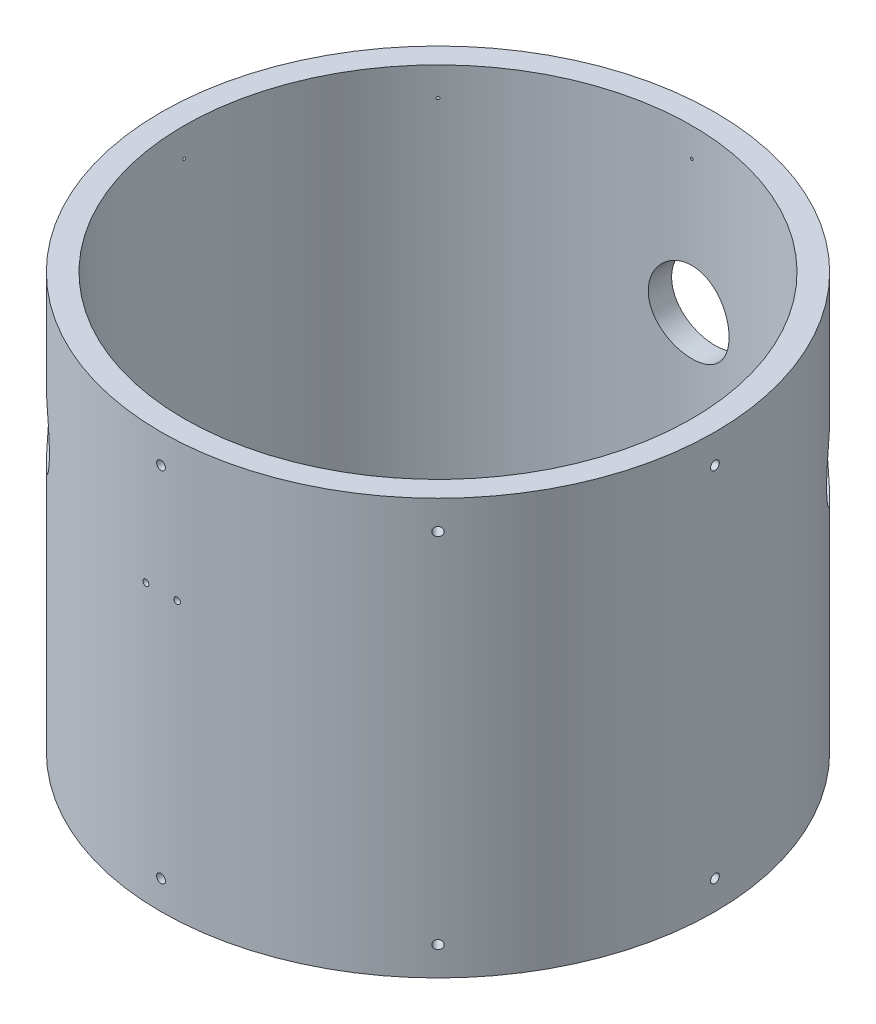
from build123d import *

# Parameters (mm, degrees)
SKETCH1_R                       = 152.4
SKETCH1_R_2                     = 139.7
BOSS_EXTRUDE1_DEPTH             = 228.6
F_10_32_TAPPED_HOLE1_AT_2_COUNT = 2
F_10_32_TAPPED_HOLE1_AT_2_PITCH = 196.85
CIRPATTERN1_COUNT               = 8
F_8_32_TAPPED_HOLE1_D           = 3.4544
F_8_32_TAPPED_HOLE1_DEPTH       = 10.668
F_8_32_TAPPED_HOLE1_TIP         = 1.037806461
PRESSURE_RELIF_HOLE_REACH       = 435.16
PRESSURE_RELIF_HOLE_BORE_R      = 19.05
VENT_VALVE_HOLE_D               = 38.1
VENT_VALVE_HOLE_DEPTH           = 25.4
HELIUM_IN_REACH                 = 412.35
HELIUM_IN_BORE_R                = 22.225


with BuildPart() as part:
    # Sketch1 → Boss-Extrude1 (new body)
    with BuildSketch(Plane(origin=(0, 0, 0), x_dir=(1, 0, 0), z_dir=(0, 1, 0))):
        with Locations(Location((0, 0, 0), (0, 0, 270))):
            Circle(SKETCH1_R)
        with Locations(Location((0, 0, 0), (0, 0, 270))):
            Circle(SKETCH1_R_2, mode=Mode.SUBTRACT)
    extrude(amount=BOSS_EXTRUDE1_DEPTH)

    # Sketch3 → #10-32 Tapped Hole1 (revolve, cut)
    with BuildSketch(Plane(origin=(0, 212.725, 152.4), x_dir=(0, -1, 0), z_dir=(1, 0, 0))):
        Polygon((0, 0), (0, 13.151317848), (2.0193, 11.938), (2.0193, 9.652), (2.413, 9.652), (2.413, 0), align=None)
    f_10_32_tapped_hole1 = revolve(axis=Axis((0, 212.725, 158.75), (0, 0, -1)), mode=Mode.SUBTRACT)

    # #10-32 Tapped Hole1 at 2: #10-32 Tapped Hole1 ×2
    with Locations(*[(0, -i * F_10_32_TAPPED_HOLE1_AT_2_PITCH, 0) for i in range(1, F_10_32_TAPPED_HOLE1_AT_2_COUNT)]):
        add(f_10_32_tapped_hole1, mode=Mode.SUBTRACT)

    # CirPattern1: #10-32 Tapped Hole1 ×8 about axis
    cirpattern1_axis = Axis((0, 0, 0), (0, 1, 0))
    for i in range(1, CIRPATTERN1_COUNT):
        add(f_10_32_tapped_hole1.rotate(cirpattern1_axis, i * 360 / CIRPATTERN1_COUNT), mode=Mode.SUBTRACT)

    # CirPattern1 copy 1 sketch → CirPattern1 copy 1 (revolve, cut)
    with BuildSketch(Plane(origin=(107.763073453, 15.875, 107.763073453), x_dir=(0, -1, 0), z_dir=(0.7071067811865476, 0, -0.7071067811865475))):
        Polygon((0, 0), (0, 13.151317848), (2.0193, 11.938), (2.0193, 9.652), (2.413, 9.652), (2.413, 0), align=None)
    revolve(axis=Axis((112.253201513, 15.875, 112.253201513), (-0.7071067811865475, 0, -0.7071067811865476)), mode=Mode.SUBTRACT)

    # CirPattern1 copy 2 sketch → CirPattern1 copy 2 (revolve, cut)
    with BuildSketch(Plane(origin=(152.4, 15.875, 0), x_dir=(0, -1, 0), z_dir=(0, 0, -1))):
        Polygon((0, 0), (0, 13.151317848), (2.0193, 11.938), (2.0193, 9.652), (2.413, 9.652), (2.413, 0), align=None)
    revolve(axis=Axis((158.75, 15.875, 0), (-1, 0, 0)), mode=Mode.SUBTRACT)

    # CirPattern1 copy 3 sketch → CirPattern1 copy 3 (revolve, cut)
    with BuildSketch(Plane(origin=(107.763073453, 15.875, -107.763073453), x_dir=(0, -1, 0), z_dir=(-0.7071067811865475, 0, -0.7071067811865476))):
        Polygon((0, 0), (0, 13.151317848), (2.0193, 11.938), (2.0193, 9.652), (2.413, 9.652), (2.413, 0), align=None)
    revolve(axis=Axis((112.253201513, 15.875, -112.253201513), (-0.7071067811865476, 0, 0.7071067811865475)), mode=Mode.SUBTRACT)

    # CirPattern1 copy 4 sketch → CirPattern1 copy 4 (revolve, cut)
    with BuildSketch(Plane(origin=(0, 15.875, -152.4), x_dir=(0, -1, 0), z_dir=(-1, 0, 0))):
        Polygon((0, 0), (0, 13.151317848), (2.0193, 11.938), (2.0193, 9.652), (2.413, 9.652), (2.413, 0), align=None)
    revolve(axis=Axis((0, 15.875, -158.75), (0, 0, 1)), mode=Mode.SUBTRACT)

    # CirPattern1 copy 5 sketch → CirPattern1 copy 5 (revolve, cut)
    with BuildSketch(Plane(origin=(-107.763073453, 15.875, -107.763073453), x_dir=(0, -1, 0), z_dir=(-0.7071067811865477, 0, 0.7071067811865475))):
        Polygon((0, 0), (0, 13.151317848), (2.0193, 11.938), (2.0193, 9.652), (2.413, 9.652), (2.413, 0), align=None)
    revolve(axis=Axis((-112.253201513, 15.875, -112.253201513), (0.7071067811865475, 0, 0.7071067811865477)), mode=Mode.SUBTRACT)

    # CirPattern1 copy 6 sketch → CirPattern1 copy 6 (revolve, cut)
    with BuildSketch(Plane(origin=(-152.4, 15.875, 0), x_dir=(0, -1, 0), z_dir=(0, 0, 1))):
        Polygon((0, 0), (0, 13.151317848), (2.0193, 11.938), (2.0193, 9.652), (2.413, 9.652), (2.413, 0), align=None)
    revolve(axis=Axis((-158.75, 15.875, 0), (1, 0, 0)), mode=Mode.SUBTRACT)

    # CirPattern1 copy 7 sketch → CirPattern1 copy 7 (revolve, cut)
    with BuildSketch(Plane(origin=(-107.763073453, 15.875, 107.763073453), x_dir=(0, -1, 0), z_dir=(0.7071067811865474, 0, 0.7071067811865477))):
        Polygon((0, 0), (0, 13.151317848), (2.0193, 11.938), (2.0193, 9.652), (2.413, 9.652), (2.413, 0), align=None)
    revolve(axis=Axis((-112.253201513, 15.875, 112.253201513), (0.7071067811865477, 0, -0.7071067811865474)), mode=Mode.SUBTRACT)

    # #8-32 Tapped Hole1
    with Locations(Plane.XY.offset(152.4)):
        with Locations((-8.5725, 152.4), (8.5725, 152.4)):
            Hole(F_8_32_TAPPED_HOLE1_D / 2, depth=F_8_32_TAPPED_HOLE1_DEPTH)
            with Locations((0, 0, -(F_8_32_TAPPED_HOLE1_DEPTH + F_8_32_TAPPED_HOLE1_TIP / 2))):  # 118° drill point
                Cone(0, F_8_32_TAPPED_HOLE1_D / 2, F_8_32_TAPPED_HOLE1_TIP, mode=Mode.SUBTRACT)

    # Pressure Relif Hole bore → Pressure Relif Hole (cut, up to next)
    with BuildSketch(Plane(origin=(107.763073453, 0, -107.763073453), x_dir=(-0.7071067811865465, 0, -0.7071067811865487), z_dir=(0.7071067811865487, 0, -0.7071067811865465)), mode=Mode.PRIVATE) as pressure_relif_hole_sk1:
        with Locations((0, 139.7)):
            Circle(PRESSURE_RELIF_HOLE_BORE_R)
    pressure_relif_hole_tool1 = extrude(pressure_relif_hole_sk1.sketch, amount=-PRESSURE_RELIF_HOLE_REACH, mode=Mode.PRIVATE) & part.part
    add(pressure_relif_hole_tool1.solids().sort_by_distance((107.763073, 139.7, -107.763073))[0], mode=Mode.SUBTRACT)

    # Vent Valve Hole
    with Locations(Plane(origin=(-107.763073453, 0, 107.763073453), x_dir=(0, -1, 0), z_dir=(-0.7071067811865488, 0, 0.7071067811865464))):
        with Locations((-155.575, 0)):
            Hole(VENT_VALVE_HOLE_D / 2, depth=VENT_VALVE_HOLE_DEPTH)

    # Helium In bore → Helium In (cut, up to next)
    with BuildSketch(Plane(origin=(0, 0, -152.4), x_dir=(0, -1, 0), z_dir=(0, 0, -1)), mode=Mode.PRIVATE) as helium_in_sk1:
        with Locations((-139.7, 0)):
            Circle(HELIUM_IN_BORE_R)
    helium_in_tool1 = extrude(helium_in_sk1.sketch, amount=-HELIUM_IN_REACH, mode=Mode.PRIVATE) & part.part
    add(helium_in_tool1.solids().sort_by_distance((0, 139.7, -152.4))[0], mode=Mode.SUBTRACT)


solid = part.part
